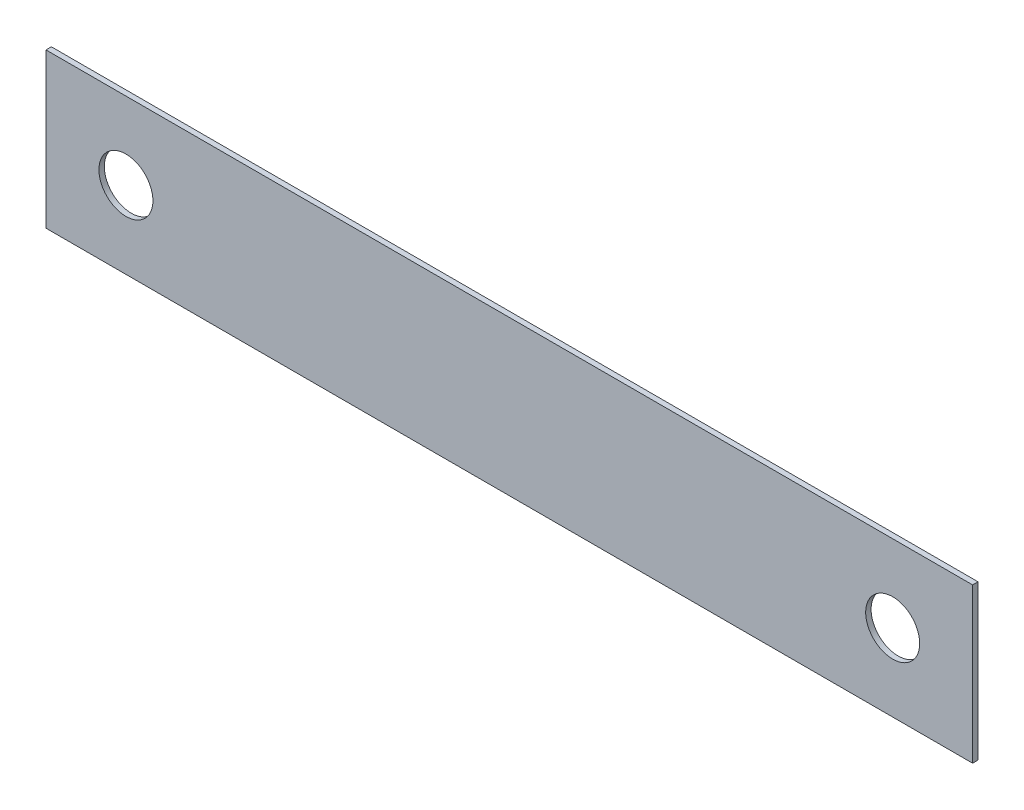
from build123d import *

# Parameters (mm, degrees)
SKETCH1_W           = 85.8
SKETCH1_H           = 14.3
SKETCH1_R           = 2.5
BOSS_EXTRUDE1_DEPTH = 0.5


with BuildPart() as part:
    # Sketch1 → Boss-Extrude1 (new body)
    with BuildSketch(Plane.XY):
        with Locations((42.9, 7.15)):
            Rectangle(SKETCH1_W, SKETCH1_H)
        with Locations((7.4, 7.15)):
            Circle(SKETCH1_R, mode=Mode.SUBTRACT)
        with Locations((78.4, 7.15)):
            Circle(SKETCH1_R, mode=Mode.SUBTRACT)
    extrude(amount=BOSS_EXTRUDE1_DEPTH)


solid = part.part
